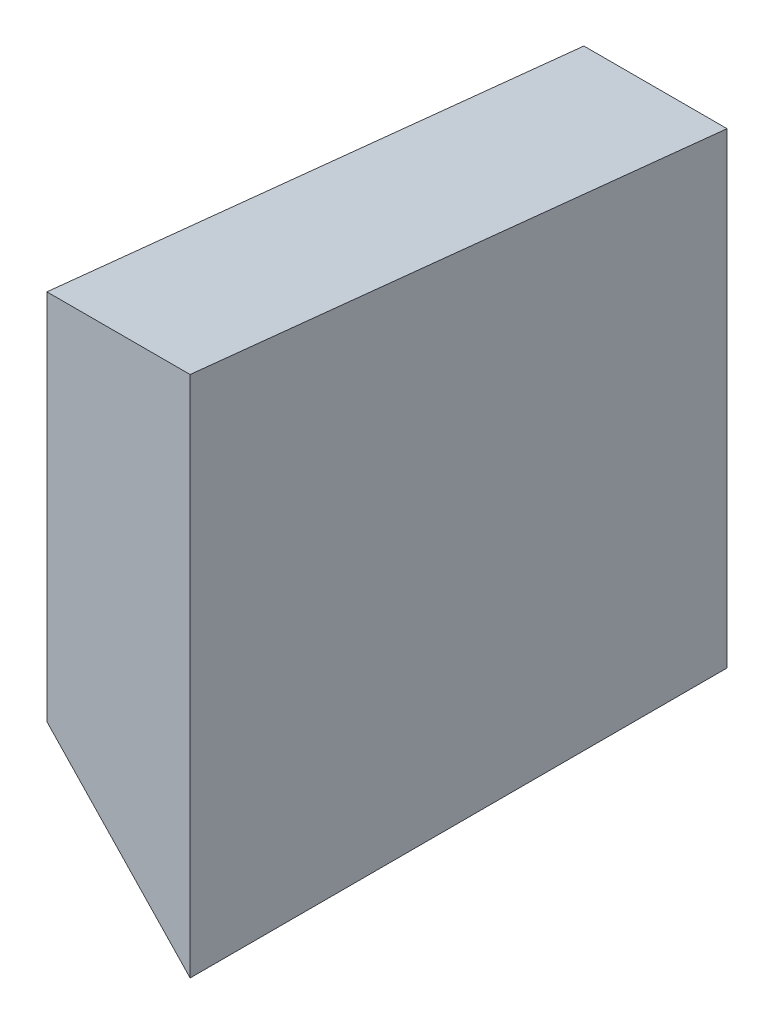
from build123d import *

# Parameters (mm, degrees)
ESQUISSE1_W             = 5.08
ESQUISSE1_H             = 19.05
BOSS_EXTRU_1_DEPTH      = 20.828
ENL_V_MAT_EXTRU_1_DEPTH = 6.08
ENL_V_MAT_EXTRU_2_DEPTH = 20.05


with BuildPart() as part:
    # Esquisse1 → Boss.-Extru.1 (new body)
    with BuildSketch(Plane(origin=(0, 0, 0), x_dir=(1, 0, 0), z_dir=(0, 1, 0))):
        with Locations((0, -9.525)):
            Rectangle(ESQUISSE1_W, ESQUISSE1_H)
    extrude(amount=-BOSS_EXTRU_1_DEPTH)

    # Esquisse2 → Enlèv. mat.-Extru.1 (cut, through all)
    with BuildSketch(Plane(origin=(2.54, 0, 0), x_dir=(0, 0, -1), z_dir=(1, 0, 0))):
        Polygon((0, -1.971986417), (-19.05, 0), (0, 0), align=None)
    extrude(amount=-ENL_V_MAT_EXTRU_1_DEPTH, mode=Mode.SUBTRACT)

    # Esquisse3 → Enlèv. mat.-Extru.2 (cut, through all)
    with BuildSketch(Plane.XY.offset(19.05)):
        Polygon((-2.54, -20.828), (-2.54, -13.208), (2.54, -18.542), (2.54, -20.828), align=None)
    extrude(amount=-ENL_V_MAT_EXTRU_2_DEPTH, mode=Mode.SUBTRACT)


solid = part.part
